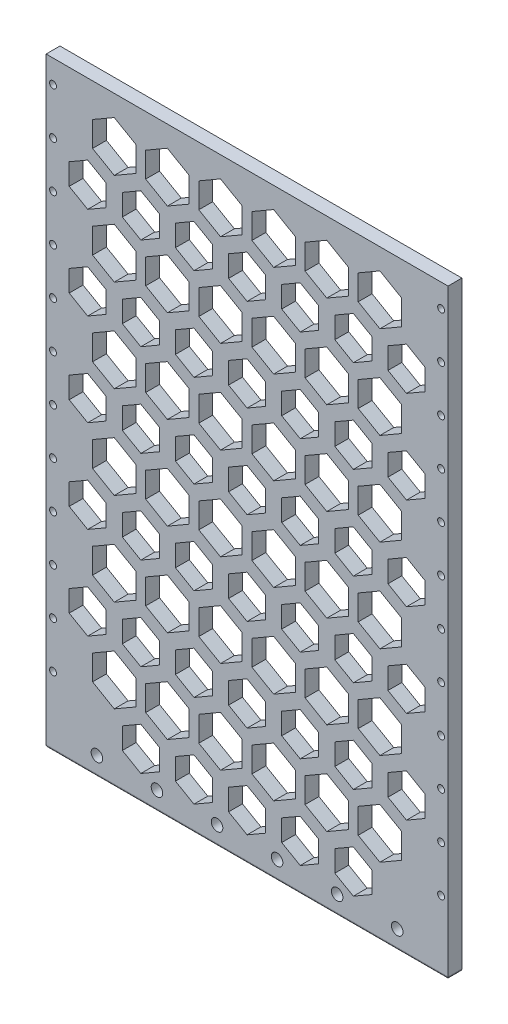
from build123d import *

# Parameters (mm, degrees)
SKETCH1_W           = 174
SKETCH1_H           = 240
BOSS_EXTRUDE1_DEPTH = 6
SKETCH3_R           = 2.5
CUT_EXTRUDE1_DEPTH  = 6
SKETCH4_W           = 174
SKETCH4_H           = 6
BOSS_EXTRUDE2_DEPTH = 20
SKETCH6_R           = 1.5
CUT_EXTRUDE2_DEPTH  = 10
CUT_EXTRUDE3_DEPTH  = 10
FILLET2_R           = 1


with BuildPart() as part:
    # Sketch1 → Boss-Extrude1 (new body)
    with BuildSketch(Plane.XY):
        with Locations((0, -30)):
            Rectangle(SKETCH1_W, SKETCH1_H)
    extrude(amount=BOSS_EXTRUDE1_DEPTH)

    # Sketch3 → Cut-Extrude1 (cut)
    with BuildSketch(Plane.XY.offset(6)):
        with Locations((-65, -142)):
            Circle(SKETCH3_R)
        with Locations((-39, -142)):
            Circle(SKETCH3_R)
        with Locations((-13, -142)):
            Circle(SKETCH3_R)
        with Locations((13, -142)):
            Circle(SKETCH3_R)
        with Locations((39, -142)):
            Circle(SKETCH3_R)
        with Locations((65, -142)):
            Circle(SKETCH3_R)
    extrude(amount=-CUT_EXTRUDE1_DEPTH, mode=Mode.SUBTRACT)

    # Sketch4 → Boss-Extrude2 (add)
    with BuildSketch(Plane(origin=(0, 90, 0), x_dir=(1, 0, 0), z_dir=(0, 1, 0))):
        with Locations((0, -3)):
            Rectangle(SKETCH4_W, SKETCH4_H)
    extrude(amount=BOSS_EXTRUDE2_DEPTH)

    # Sketch6 → Cut-Extrude2 (cut)
    with BuildSketch(Plane.XY.offset(6)):
        with Locations((-84, 100)):
            Circle(SKETCH6_R)
        with Locations((-84, 80)):
            Circle(SKETCH6_R)
        with Locations((-84, 60)):
            Circle(SKETCH6_R)
        with Locations((-84, 40)):
            Circle(SKETCH6_R)
        with Locations((-84, 20)):
            Circle(SKETCH6_R)
        with Locations((-84, 0)):
            Circle(SKETCH6_R)
        with Locations((-84, -20)):
            Circle(SKETCH6_R)
        with Locations((-84, -40)):
            Circle(SKETCH6_R)
        with Locations((-84, -60)):
            Circle(SKETCH6_R)
        with Locations((-84, -80)):
            Circle(SKETCH6_R)
        with Locations((-84, -100)):
            Circle(SKETCH6_R)
        with Locations((-84, -120)):
            Circle(SKETCH6_R)
        with Locations((84, 100)):
            Circle(SKETCH6_R)
        with Locations((84, 80)):
            Circle(SKETCH6_R)
        with Locations((84, 60)):
            Circle(SKETCH6_R)
        with Locations((84, 40)):
            Circle(SKETCH6_R)
        with Locations((84, 20)):
            Circle(SKETCH6_R)
        with Locations((84, 0)):
            Circle(SKETCH6_R)
        with Locations((84, -20)):
            Circle(SKETCH6_R)
        with Locations((84, -40)):
            Circle(SKETCH6_R)
        with Locations((84, -60)):
            Circle(SKETCH6_R)
        with Locations((84, -80)):
            Circle(SKETCH6_R)
        with Locations((84, -100)):
            Circle(SKETCH6_R)
        with Locations((84, -120)):
            Circle(SKETCH6_R)
    extrude(amount=-CUT_EXTRUDE2_DEPTH, mode=Mode.SUBTRACT)

    # Sketch7 → Cut-Extrude3 (cut)
    with BuildSketch(Plane.XY.offset(6)):
        Polygon((-46, 60.762395693), (-38, 65.381197846), (-38, 74.618802154), (-46, 79.237604307), (-54, 74.618802154), (-54, 65.381197846), align=None)
        Polygon((-23, 60.762395693), (-15, 65.381197846), (-15, 74.618802154), (-23, 79.237604307), (-31, 74.618802154), (-31, 65.381197846), align=None)
        Polygon((0, 60.762395693), (8, 65.381197846), (8, 74.618802154), (0, 79.237604307), (-8, 74.618802154), (-8, 65.381197846), align=None)
        Polygon((23, 60.762395693), (31, 65.381197846), (31, 74.618802154), (23, 79.237604307), (15, 74.618802154), (15, 65.381197846), align=None)
        Polygon((46, 60.762395693), (54, 65.381197846), (54, 74.618802154), (46, 79.237604307), (38, 74.618802154), (38, 65.381197846), align=None)
        Polygon((69, 60.762395693), (77, 65.381197846), (77, 74.618802154), (69, 79.237604307), (61, 74.618802154), (61, 65.381197846), align=None)
        Polygon((-46, 20.762395693), (-38, 25.381197846), (-38, 34.618802154), (-46, 39.237604307), (-54, 34.618802154), (-54, 25.381197846), align=None)
        Polygon((-23, 20.762395693), (-15, 25.381197846), (-15, 34.618802154), (-23, 39.237604307), (-31, 34.618802154), (-31, 25.381197846), align=None)
        Polygon((0, 20.762395693), (8, 25.381197846), (8, 34.618802154), (0, 39.237604307), (-8, 34.618802154), (-8, 25.381197846), align=None)
        Polygon((23, 20.762395693), (31, 25.381197846), (31, 34.618802154), (23, 39.237604307), (15, 34.618802154), (15, 25.381197846), align=None)
        Polygon((46, 20.762395693), (54, 25.381197846), (54, 34.618802154), (46, 39.237604307), (38, 34.618802154), (38, 25.381197846), align=None)
        Polygon((69, 20.762395693), (77, 25.381197846), (77, 34.618802154), (69, 39.237604307), (61, 34.618802154), (61, 25.381197846), align=None)
        Polygon((-46, -19.237604307), (-38, -14.618802154), (-38, -5.381197846), (-46, -0.762395693), (-54, -5.381197846), (-54, -14.618802154), align=None)
        Polygon((-23, -19.237604307), (-15, -14.618802154), (-15, -5.381197846), (-23, -0.762395693), (-31, -5.381197846), (-31, -14.618802154), align=None)
        Polygon((0, -19.237604307), (8, -14.618802154), (8, -5.381197846), (0, -0.762395693), (-8, -5.381197846), (-8, -14.618802154), align=None)
        Polygon((23, -19.237604307), (31, -14.618802154), (31, -5.381197846), (23, -0.762395693), (15, -5.381197846), (15, -14.618802154), align=None)
        Polygon((46, -19.237604307), (54, -14.618802154), (54, -5.381197846), (46, -0.762395693), (38, -5.381197846), (38, -14.618802154), align=None)
        Polygon((69, -19.237604307), (77, -14.618802154), (77, -5.381197846), (69, -0.762395693), (61, -5.381197846), (61, -14.618802154), align=None)
        Polygon((-46, -59.237604307), (-38, -54.618802154), (-38, -45.381197846), (-46, -40.762395693), (-54, -45.381197846), (-54, -54.618802154), align=None)
        Polygon((-23, -59.237604307), (-15, -54.618802154), (-15, -45.381197846), (-23, -40.762395693), (-31, -45.381197846), (-31, -54.618802154), align=None)
        Polygon((0, -59.237604307), (8, -54.618802154), (8, -45.381197846), (0, -40.762395693), (-8, -45.381197846), (-8, -54.618802154), align=None)
        Polygon((23, -59.237604307), (31, -54.618802154), (31, -45.381197846), (23, -40.762395693), (15, -45.381197846), (15, -54.618802154), align=None)
        Polygon((46, -59.237604307), (54, -54.618802154), (54, -45.381197846), (46, -40.762395693), (38, -45.381197846), (38, -54.618802154), align=None)
        Polygon((69, -59.237604307), (77, -54.618802154), (77, -45.381197846), (69, -40.762395693), (61, -45.381197846), (61, -54.618802154), align=None)
        Polygon((-46, -99.237604307), (-38, -94.618802154), (-38, -85.381197846), (-46, -80.762395693), (-54, -85.381197846), (-54, -94.618802154), align=None)
        Polygon((-23, -99.237604307), (-15, -94.618802154), (-15, -85.381197846), (-23, -80.762395693), (-31, -85.381197846), (-31, -94.618802154), align=None)
        Polygon((0, -99.237604307), (8, -94.618802154), (8, -85.381197846), (0, -80.762395693), (-8, -85.381197846), (-8, -94.618802154), align=None)
        Polygon((23, -99.237604307), (31, -94.618802154), (31, -85.381197846), (23, -80.762395693), (15, -85.381197846), (15, -94.618802154), align=None)
        Polygon((46, -99.237604307), (54, -94.618802154), (54, -85.381197846), (46, -80.762395693), (38, -85.381197846), (38, -94.618802154), align=None)
        Polygon((69, -99.237604307), (77, -94.618802154), (77, -85.381197846), (69, -80.762395693), (61, -85.381197846), (61, -94.618802154), align=None)
        Polygon((-46, -139.237604307), (-38, -134.618802154), (-38, -125.381197846), (-46, -120.762395693), (-54, -125.381197846), (-54, -134.618802154), align=None)
        Polygon((-23, -139.237604307), (-15, -134.618802154), (-15, -125.381197846), (-23, -120.762395693), (-31, -125.381197846), (-31, -134.618802154), align=None)
        Polygon((0, -139.237604307), (8, -134.618802154), (8, -125.381197846), (0, -120.762395693), (-8, -125.381197846), (-8, -134.618802154), align=None)
        Polygon((23, -139.237604307), (31, -134.618802154), (31, -125.381197846), (23, -120.762395693), (15, -125.381197846), (15, -134.618802154), align=None)
        Polygon((46, -139.237604307), (54, -134.618802154), (54, -125.381197846), (46, -120.762395693), (38, -125.381197846), (38, -134.618802154), align=None)
        Polygon((-69, 60.762395693), (-61, 65.381197846), (-61, 74.618802154), (-69, 79.237604307), (-77, 74.618802154), (-77, 65.381197846), align=None)
        Polygon((-69, 20.762395693), (-61, 25.381197846), (-61, 34.618802154), (-69, 39.237604307), (-77, 34.618802154), (-77, 25.381197846), align=None)
        Polygon((-69, -19.237604307), (-61, -14.618802154), (-61, -5.381197846), (-69, -0.762395693), (-77, -5.381197846), (-77, -14.618802154), align=None)
        Polygon((-69, -59.237604307), (-61, -54.618802154), (-61, -45.381197846), (-69, -40.762395693), (-77, -45.381197846), (-77, -54.618802154), align=None)
        Polygon((-69, -99.237604307), (-61, -94.618802154), (-61, -85.381197846), (-69, -80.762395693), (-77, -85.381197846), (-77, -94.618802154), align=None)
        Polygon((-34.5, 79.237604307), (-25.108983849, 84.65951001), (-25.108983849, 95.503321416), (-34.5, 100.925227119), (-43.891016151, 95.503321416), (-43.891016151, 84.65951001), align=None)
        Polygon((-11.5, 79.237604307), (-2.108983849, 84.65951001), (-2.108983849, 95.503321416), (-11.5, 100.925227119), (-20.891016151, 95.503321416), (-20.891016151, 84.65951001), align=None)
        Polygon((11.5, 79.237604307), (20.891016151, 84.65951001), (20.891016151, 95.503321416), (11.5, 100.925227119), (2.108983849, 95.503321416), (2.108983849, 84.65951001), align=None)
        Polygon((34.5, 79.237604307), (43.891016151, 84.65951001), (43.891016151, 95.503321416), (34.5, 100.925227119), (25.108983849, 95.503321416), (25.108983849, 84.65951001), align=None)
        Polygon((57.5, 79.237604307), (66.891016151, 84.65951001), (66.891016151, 95.503321416), (57.5, 100.925227119), (48.108983849, 95.503321416), (48.108983849, 84.65951001), align=None)
        Polygon((-34.5, 39.237604307), (-25.108983849, 44.65951001), (-25.108983849, 55.503321416), (-34.5, 60.925227119), (-43.891016151, 55.503321416), (-43.891016151, 44.65951001), align=None)
        Polygon((-11.5, 39.237604307), (-2.108983849, 44.65951001), (-2.108983849, 55.503321416), (-11.5, 60.925227119), (-20.891016151, 55.503321416), (-20.891016151, 44.65951001), align=None)
        Polygon((11.5, 39.237604307), (20.891016151, 44.65951001), (20.891016151, 55.503321416), (11.5, 60.925227119), (2.108983849, 55.503321416), (2.108983849, 44.65951001), align=None)
        Polygon((34.5, 39.237604307), (43.891016151, 44.65951001), (43.891016151, 55.503321416), (34.5, 60.925227119), (25.108983849, 55.503321416), (25.108983849, 44.65951001), align=None)
        Polygon((57.5, 39.237604307), (66.891016151, 44.65951001), (66.891016151, 55.503321416), (57.5, 60.925227119), (48.108983849, 55.503321416), (48.108983849, 44.65951001), align=None)
        Polygon((-34.5, -0.762395693), (-25.108983849, 4.65951001), (-25.108983849, 15.503321416), (-34.5, 20.925227119), (-43.891016151, 15.503321416), (-43.891016151, 4.65951001), align=None)
        Polygon((-11.5, -0.762395693), (-2.108983849, 4.65951001), (-2.108983849, 15.503321416), (-11.5, 20.925227119), (-20.891016151, 15.503321416), (-20.891016151, 4.65951001), align=None)
        Polygon((11.5, -0.762395693), (20.891016151, 4.65951001), (20.891016151, 15.503321416), (11.5, 20.925227119), (2.108983849, 15.503321416), (2.108983849, 4.65951001), align=None)
        Polygon((34.5, -0.762395693), (43.891016151, 4.65951001), (43.891016151, 15.503321416), (34.5, 20.925227119), (25.108983849, 15.503321416), (25.108983849, 4.65951001), align=None)
        Polygon((57.5, -0.762395693), (66.891016151, 4.65951001), (66.891016151, 15.503321416), (57.5, 20.925227119), (48.108983849, 15.503321416), (48.108983849, 4.65951001), align=None)
        Polygon((-34.5, -40.762395693), (-25.108983849, -35.34048999), (-25.108983849, -24.496678584), (-34.5, -19.074772881), (-43.891016151, -24.496678584), (-43.891016151, -35.34048999), align=None)
        Polygon((-11.5, -40.762395693), (-2.108983849, -35.34048999), (-2.108983849, -24.496678584), (-11.5, -19.074772881), (-20.891016151, -24.496678584), (-20.891016151, -35.34048999), align=None)
        Polygon((11.5, -40.762395693), (20.891016151, -35.34048999), (20.891016151, -24.496678584), (11.5, -19.074772881), (2.108983849, -24.496678584), (2.108983849, -35.34048999), align=None)
        Polygon((34.5, -40.762395693), (43.891016151, -35.34048999), (43.891016151, -24.496678584), (34.5, -19.074772881), (25.108983849, -24.496678584), (25.108983849, -35.34048999), align=None)
        Polygon((57.5, -40.762395693), (66.891016151, -35.34048999), (66.891016151, -24.496678584), (57.5, -19.074772881), (48.108983849, -24.496678584), (48.108983849, -35.34048999), align=None)
        Polygon((-34.5, -80.762395693), (-25.108983849, -75.34048999), (-25.108983849, -64.496678584), (-34.5, -59.074772881), (-43.891016151, -64.496678584), (-43.891016151, -75.34048999), align=None)
        Polygon((-11.5, -80.762395693), (-2.108983849, -75.34048999), (-2.108983849, -64.496678584), (-11.5, -59.074772881), (-20.891016151, -64.496678584), (-20.891016151, -75.34048999), align=None)
        Polygon((11.5, -80.762395693), (20.891016151, -75.34048999), (20.891016151, -64.496678584), (11.5, -59.074772881), (2.108983849, -64.496678584), (2.108983849, -75.34048999), align=None)
        Polygon((34.5, -80.762395693), (43.891016151, -75.34048999), (43.891016151, -64.496678584), (34.5, -59.074772881), (25.108983849, -64.496678584), (25.108983849, -75.34048999), align=None)
        Polygon((57.5, -80.762395693), (66.891016151, -75.34048999), (66.891016151, -64.496678584), (57.5, -59.074772881), (48.108983849, -64.496678584), (48.108983849, -75.34048999), align=None)
        Polygon((-34.5, -120.762395693), (-25.108983849, -115.34048999), (-25.108983849, -104.496678584), (-34.5, -99.074772881), (-43.891016151, -104.496678584), (-43.891016151, -115.34048999), align=None)
        Polygon((-11.5, -120.762395693), (-2.108983849, -115.34048999), (-2.108983849, -104.496678584), (-11.5, -99.074772881), (-20.891016151, -104.496678584), (-20.891016151, -115.34048999), align=None)
        Polygon((11.5, -120.762395693), (20.891016151, -115.34048999), (20.891016151, -104.496678584), (11.5, -99.074772881), (2.108983849, -104.496678584), (2.108983849, -115.34048999), align=None)
        Polygon((34.5, -120.762395693), (43.891016151, -115.34048999), (43.891016151, -104.496678584), (34.5, -99.074772881), (25.108983849, -104.496678584), (25.108983849, -115.34048999), align=None)
        Polygon((57.5, -120.762395693), (66.891016151, -115.34048999), (66.891016151, -104.496678584), (57.5, -99.074772881), (48.108983849, -104.496678584), (48.108983849, -115.34048999), align=None)
        Polygon((-57.5, 79.237604307), (-48.108983849, 84.65951001), (-48.108983849, 95.503321416), (-57.5, 100.925227119), (-66.891016151, 95.503321416), (-66.891016151, 84.65951001), align=None)
        Polygon((-57.5, 39.237604307), (-48.108983849, 44.65951001), (-48.108983849, 55.503321416), (-57.5, 60.925227119), (-66.891016151, 55.503321416), (-66.891016151, 44.65951001), align=None)
        Polygon((-57.5, -0.762395693), (-48.108983849, 4.65951001), (-48.108983849, 15.503321416), (-57.5, 20.925227119), (-66.891016151, 15.503321416), (-66.891016151, 4.65951001), align=None)
        Polygon((-57.5, -40.762395693), (-48.108983849, -35.34048999), (-48.108983849, -24.496678584), (-57.5, -19.074772881), (-66.891016151, -24.496678584), (-66.891016151, -35.34048999), align=None)
        Polygon((-57.5, -80.762395693), (-48.108983849, -75.34048999), (-48.108983849, -64.496678584), (-57.5, -59.074772881), (-66.891016151, -64.496678584), (-66.891016151, -75.34048999), align=None)
        Polygon((-57.5, -120.762395693), (-48.108983849, -115.34048999), (-48.108983849, -104.496678584), (-57.5, -99.074772881), (-66.891016151, -104.496678584), (-66.891016151, -115.34048999), align=None)
    extrude(amount=-CUT_EXTRUDE3_DEPTH, mode=Mode.SUBTRACT)

    # Fillet2
    fillet2_edges = [part.edges().sort_by_distance(p)[0] for p in [
        (0, -150, 6),
        (87, -150, 3),
        (-87, -150, 3),
    ]]
    fillet(fillet2_edges, radius=FILLET2_R)


solid = part.part
